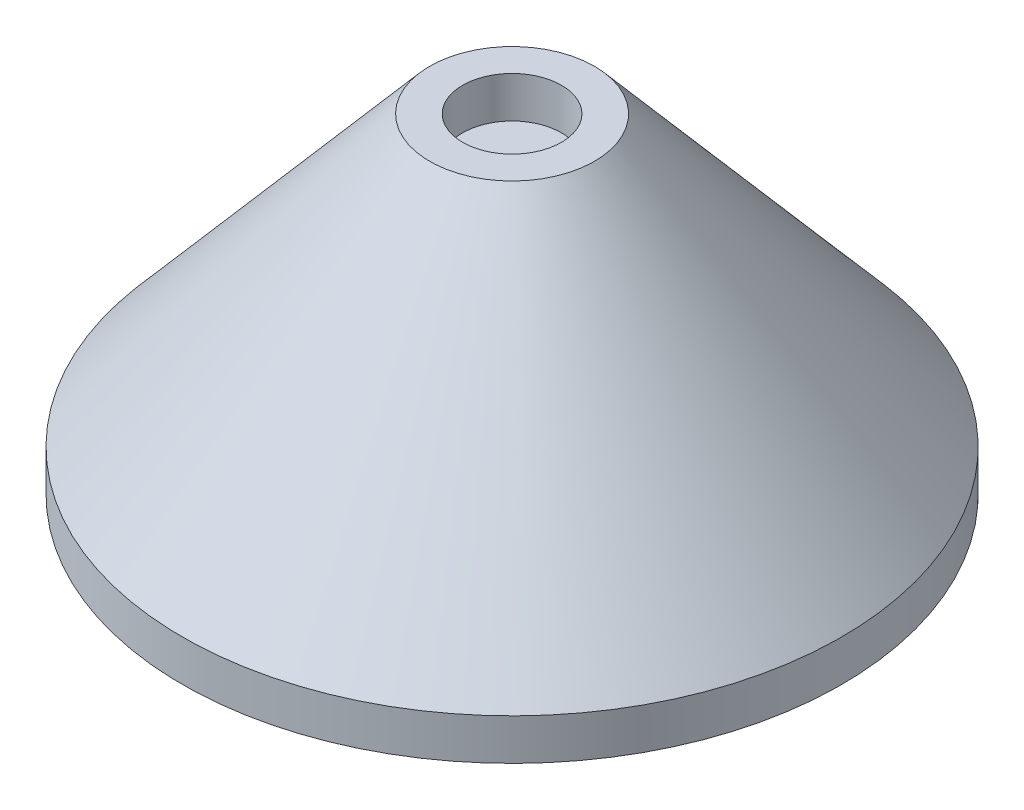
from build123d import *

# Parameters (mm, degrees)
SKETCH2_R          = 6
CUT_EXTRUDE1_DEPTH = 5


with BuildPart() as part:
    # Sketch1 → Revolve1 (revolve)
    with BuildSketch(Plane.XY):
        Polygon((0, 0), (-10, 0), (-40, -35), (-40, -40), (0, -40), align=None)
    revolve(axis=Axis((0, -40, 0), (0, 1, 0)))

    # Sketch2 → Cut-Extrude1 (cut)
    with BuildSketch(Plane(origin=(0, 0, 0), x_dir=(1, 0, 0), z_dir=(0, 1, 0))):
        Circle(SKETCH2_R)
    extrude(amount=-CUT_EXTRUDE1_DEPTH, mode=Mode.SUBTRACT)


solid = part.part
